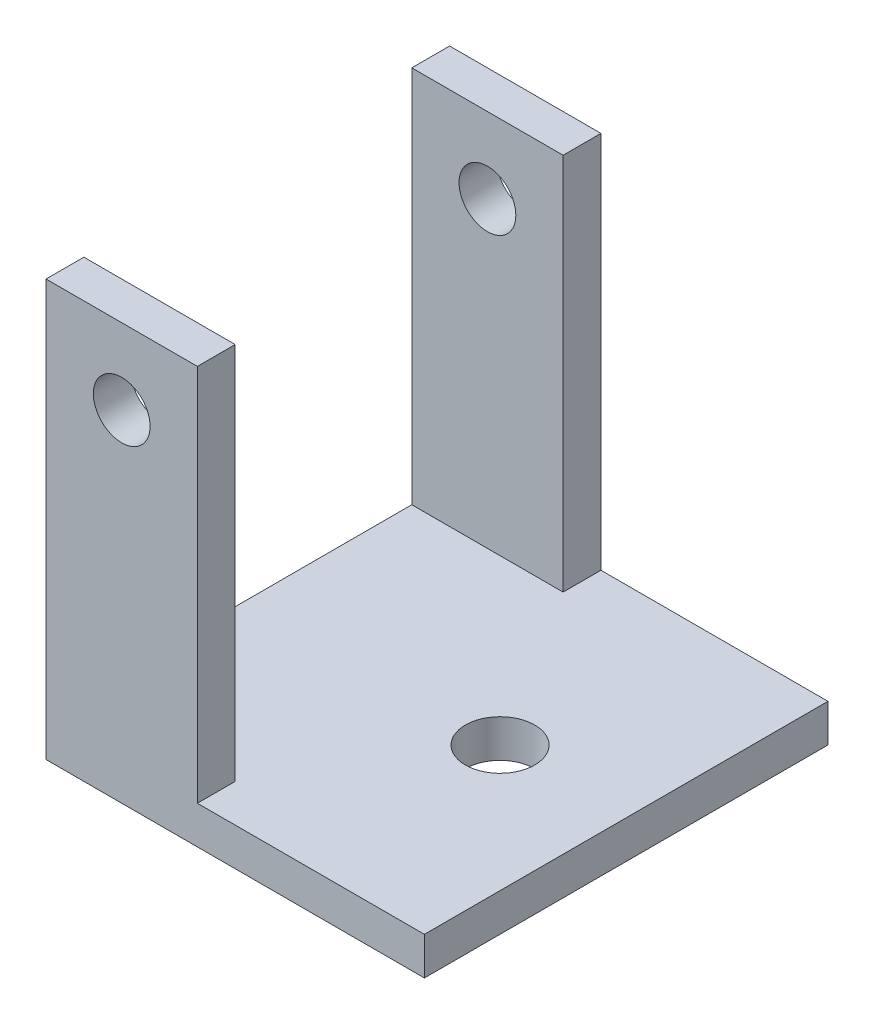
from build123d import *

# Parameters (mm, degrees)
BOSS_EXTRUDE1_DEPTH  = 3
BOSS_EXTRUDE2_DEPTH  = 13
M5_CLEARANCE_HOLE1_D = 5.5
M4_CLEARANCE_HOLE1_D = 4.5


with BuildPart() as part:
    # Sketch1 → Boss-Extrude1 (new body)
    with BuildSketch(Plane.XY):
        Polygon((0, 30), (0, -3), (30, -3), (30, 0), (12, 0), (12, 30), align=None)
    extrude(amount=BOSS_EXTRUDE1_DEPTH)

    # Sketch1_3 → Boss-Extrude2 (add)
    with BuildSketch(Plane.XY):
        Polygon((12, 0), (0, 0), (0, -3), (30, -3), (30, 0), align=None)
    extrude(amount=-BOSS_EXTRUDE2_DEPTH)

    # Mirror1: part across plane


with BuildPart() as part_1:
    add(part.part)
    add(part.part.mirror(Plane.XY.offset(-13)))

    # M5 Clearance Hole1 (through all)
    with Locations(Plane(origin=(0, 0, 0), x_dir=(1, 0, 0), z_dir=(0, 1, 0))):
        with Locations((20, 13)):
            Hole(M5_CLEARANCE_HOLE1_D / 2)

    # M4 Clearance Hole1 (through all)
    with Locations(Plane.XY.offset(3)):
        with Locations((6, 24)):
            Hole(M4_CLEARANCE_HOLE1_D / 2)


solid = part_1.part
